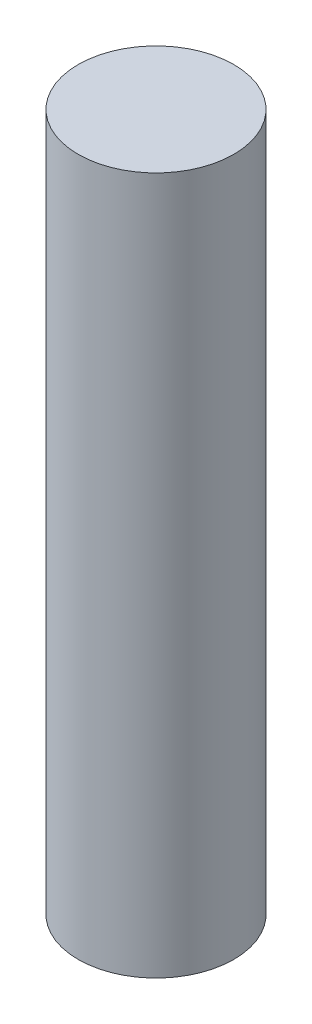
from build123d import *

# Parameters (mm, degrees)
SKETCH1_R           = 1.116025404
BOSS_EXTRUDE1_DEPTH = 10


with BuildPart() as part:
    # Sketch1 → Boss-Extrude1 (new body)
    with BuildSketch(Plane(origin=(0, 0, 0), x_dir=(1, 0, 0), z_dir=(0, 1, 0))):
        Circle(SKETCH1_R)
    extrude(amount=BOSS_EXTRUDE1_DEPTH)


solid = part.part
